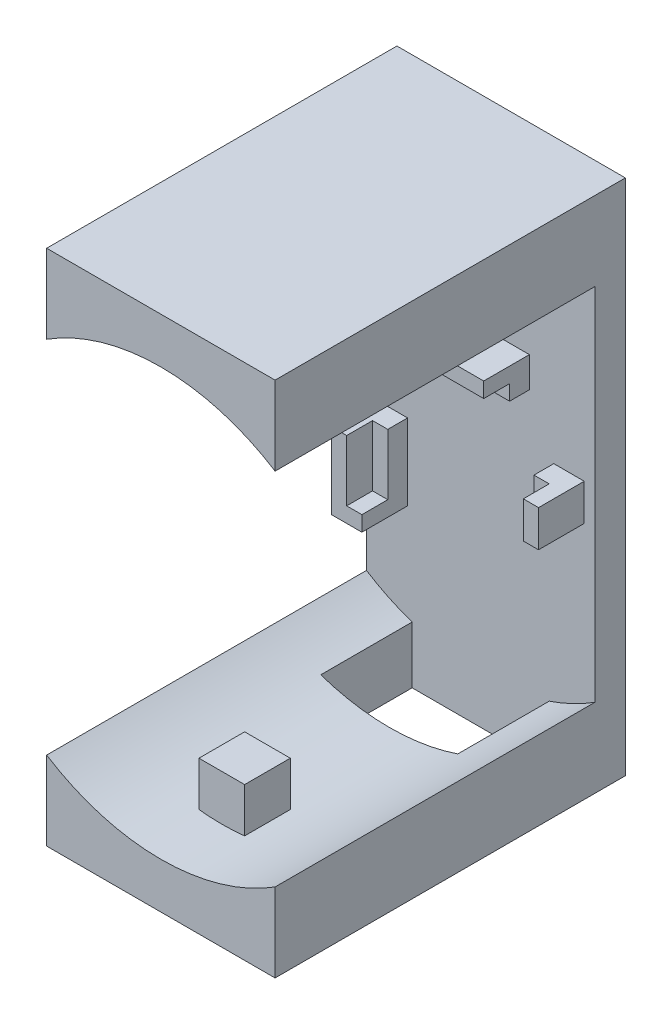
from build123d import *

# Parameters (mm, degrees)
BOSS_EXTRUDE1_DEPTH = 17
SKETCH1_3_W         = 15
SKETCH1_3_H         = 34
BOSS_EXTRUDE3_DEPTH = 2
CUT_EXTRUDE1_DEPTH  = 14
SKETCH2_W           = 1
SKETCH2_H           = 4
SKETCH2_W_2         = 6.4
SKETCH2_H_2         = 1
SKETCH2_H_3         = 2.4
BOSS_EXTRUDE5_DEPTH = 1.3
SKETCH2_3_W         = 6.4
SKETCH2_3_H         = 1
SKETCH2_3_W_2       = 1
SKETCH2_3_H_2       = 2.4
BOSS_EXTRUDE6_DEPTH = 3
CUT_EXTRUDE3_REACH  = 36
SKETCH5_W           = 9
SKETCH5_H           = 6
BOSS_EXTRUDE7_DEPTH = 4


with BuildPart() as part:
    # Sketch1 → Boss-Extrude1 (new body)
    with BuildSketch(Plane.XY):
        with BuildLine():
            Line((7.5, 17), (-7.5, 17))
            Line((-7.5, 17), (-7.5, 11.821590418))
            ThreePointArc((-7.5, 11.821590418), (-4.620629037, 13.21551313), (-1.5, 13.919410907))
            Line((-1.5, 13.919410907), (-1.5, 14))
            Line((-1.5, 14), (0, 14))
            Line((0, 14), (1.5, 14))
            Line((1.5, 14), (1.5, 13.919410907))
            ThreePointArc((1.5, 13.919410907), (4.620629037, 13.21551313), (7.5, 11.821590418))
            Line((7.5, 11.821590418), (7.5, 17))
        make_face()
        with BuildLine():
            ThreePointArc((0, 14), (-0.751081654, 13.979838209), (-1.5, 13.919410907))
            Line((-1.5, 13.919410907), (-1.5, 11))
            Line((-1.5, 11), (1.5, 11))
            Line((1.5, 11), (1.5, 13.919410907))
            ThreePointArc((1.5, 13.919410907), (0.751081654, 13.979838209), (0, 14))
        make_face()
        with BuildLine():
            Line((-1.5, -11), (-1.5, -13.919410907))
            ThreePointArc((-1.5, -13.919410907), (-0.751081654, -13.979838209), (0, -14))
            ThreePointArc((0, -14), (0.751081654, -13.979838209), (1.5, -13.919410907))
            Line((1.5, -13.919410907), (1.5, -11))
            Line((1.5, -11), (-1.5, -11))
        make_face()
        with BuildLine():
            ThreePointArc((-1.5, -13.919410907), (-4.620629037, -13.21551313), (-7.5, -11.821590418))
            Line((-7.5, -11.821590418), (-7.5, -17))
            Line((-7.5, -17), (7.5, -17))
            Line((7.5, -17), (7.5, -11.821590418))
            ThreePointArc((7.5, -11.821590418), (4.620629037, -13.21551313), (1.5, -13.919410907))
            Line((1.5, -13.919410907), (1.5, -14))
            Line((1.5, -14), (0, -14))
            Line((0, -14), (-1.5, -14))
            Line((-1.5, -14), (-1.5, -13.919410907))
        make_face()
        with BuildLine():
            ThreePointArc((0, 14), (0.751081654, 13.979838209), (1.5, 13.919410907))
            Line((1.5, 13.919410907), (1.5, 14))
            Line((1.5, 14), (0, 14))
        make_face()
        with BuildLine():
            Line((-1.5, 14), (-1.5, 13.919410907))
            ThreePointArc((-1.5, 13.919410907), (-0.751081654, 13.979838209), (0, 14))
            Line((0, 14), (-1.5, 14))
        make_face()
        with BuildLine():
            ThreePointArc((0, -14), (-0.751081654, -13.979838209), (-1.5, -13.919410907))
            Line((-1.5, -13.919410907), (-1.5, -14))
            Line((-1.5, -14), (0, -14))
        make_face()
        with BuildLine():
            Line((1.5, -14), (1.5, -13.919410907))
            ThreePointArc((1.5, -13.919410907), (0.751081654, -13.979838209), (0, -14))
            Line((0, -14), (1.5, -14))
        make_face()
    extrude(amount=BOSS_EXTRUDE1_DEPTH)

    # Sketch1_3 → Boss-Extrude3 (add)
    with BuildSketch(Plane.XY):
        Rectangle(SKETCH1_3_W, SKETCH1_3_H)
    extrude(amount=-BOSS_EXTRUDE3_DEPTH)

    # Sketch1_4 → Cut-Extrude1 (cut)
    with BuildSketch(Plane.XY):
        with BuildLine():
            Line((-1.5, -11), (-1.5, -13.919410907))
            ThreePointArc((-1.5, -13.919410907), (-0.751081654, -13.979838209), (0, -14))
            ThreePointArc((0, -14), (0.751081654, -13.979838209), (1.5, -13.919410907))
            Line((1.5, -13.919410907), (1.5, -11))
            Line((1.5, -11), (-1.5, -11))
        make_face()
        with BuildLine():
            ThreePointArc((0, 14), (-0.751081654, 13.979838209), (-1.5, 13.919410907))
            Line((-1.5, 13.919410907), (-1.5, 11))
            Line((-1.5, 11), (1.5, 11))
            Line((1.5, 11), (1.5, 13.919410907))
            ThreePointArc((1.5, 13.919410907), (0.751081654, 13.979838209), (0, 14))
        make_face()
    extrude(amount=CUT_EXTRUDE1_DEPTH, mode=Mode.SUBTRACT)

    # Sketch2 → Boss-Extrude5 (add)
    with BuildSketch(Plane.XY):
        with Locations((-5.3, -3.8)):
            Rectangle(SKETCH2_W, SKETCH2_H)
        with Locations((0, 4.3)):
            Rectangle(SKETCH2_W_2, SKETCH2_H_2)
        with Locations((5.3, -0.8)):
            Rectangle(SKETCH2_W, SKETCH2_H_3)
    extrude(amount=BOSS_EXTRUDE5_DEPTH)

    # Sketch2_3 → Boss-Extrude6 (add)
    with BuildSketch(Plane.XY):
        with Locations((0, 5.3)):
            Rectangle(SKETCH2_3_W, SKETCH2_3_H)
        Polygon((-5.8, -1.8), (-6.8, -1.8), (-6.8, -6.8), (-4.8, -6.8), (-4.8, -5.8), (-5.8, -5.8), align=None)
        with Locations((6.3, -0.8)):
            Rectangle(SKETCH2_3_W_2, SKETCH2_3_H_2)
    extrude(amount=BOSS_EXTRUDE6_DEPTH)

    # Sketch5 → Cut-Extrude3 (cut, up to next)
    with BuildSketch(Plane.XZ.offset(17), mode=Mode.PRIVATE) as cut_extrude3_sk1:
        with Locations((0, 3)):
            Rectangle(SKETCH5_W, SKETCH5_H)
    cut_extrude3_tool1 = extrude(cut_extrude3_sk1.sketch, amount=-CUT_EXTRUDE3_REACH, mode=Mode.PRIVATE) & part.part
    add(cut_extrude3_tool1.solids().sort_by_distance((0, -17, 3))[0], mode=Mode.SUBTRACT)

    # Sketch6 → Boss-Extrude7 (add)
    with BuildSketch(Plane.XY.offset(17)):
        with BuildLine():
            ThreePointArc((-1.5, -13.919410907), (-4.620629037, -13.21551313), (-7.5, -11.821590418))
            Line((-7.5, -11.821590418), (-7.5, -17))
            Line((-7.5, -17), (7.5, -17))
            Line((7.5, -17), (7.5, -11.821590418))
            ThreePointArc((7.5, -11.821590418), (4.620629037, -13.21551313), (1.5, -13.919410907))
            ThreePointArc((1.5, -13.919410907), (0, -14), (-1.5, -13.919410907))
        make_face()
        with BuildLine():
            ThreePointArc((1.5, 13.919410907), (4.620629037, 13.21551313), (7.5, 11.821590418))
            Line((7.5, 11.821590418), (7.5, 17))
            Line((7.5, 17), (-7.5, 17))
            Line((-7.5, 17), (-7.5, 11.821590418))
            ThreePointArc((-7.5, 11.821590418), (-4.620629037, 13.21551313), (-1.5, 13.919410907))
            ThreePointArc((-1.5, 13.919410907), (0, 14), (1.5, 13.919410907))
        make_face()
    extrude(amount=BOSS_EXTRUDE7_DEPTH)


solid = part.part
